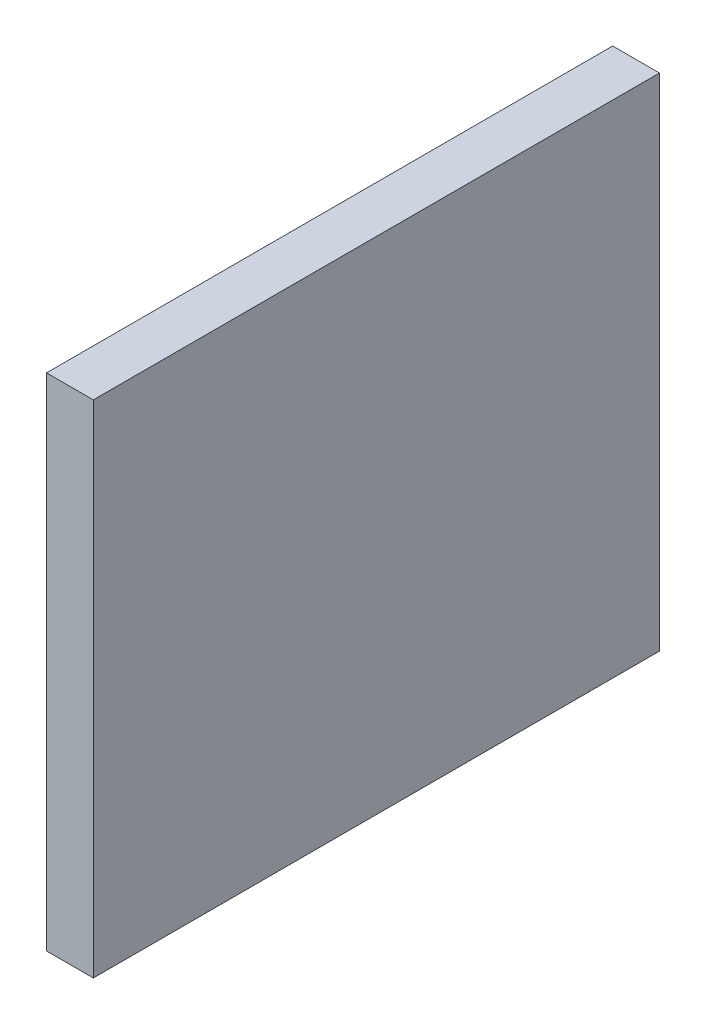
from build123d import *

# Parameters (mm, degrees)
SKETCH2_W           = 5
SKETCH2_H           = 53.502447605
BOSS_EXTRUDE1_DEPTH = 60.5


with BuildPart() as part:
    # Sketch2 → Boss-Extrude1 (new body)
    with BuildSketch(Plane.XY.offset(-331.8)):
        with Locations((-124.6, -26.751223803)):
            Rectangle(SKETCH2_W, SKETCH2_H)
    extrude(amount=BOSS_EXTRUDE1_DEPTH)


solid = part.part
